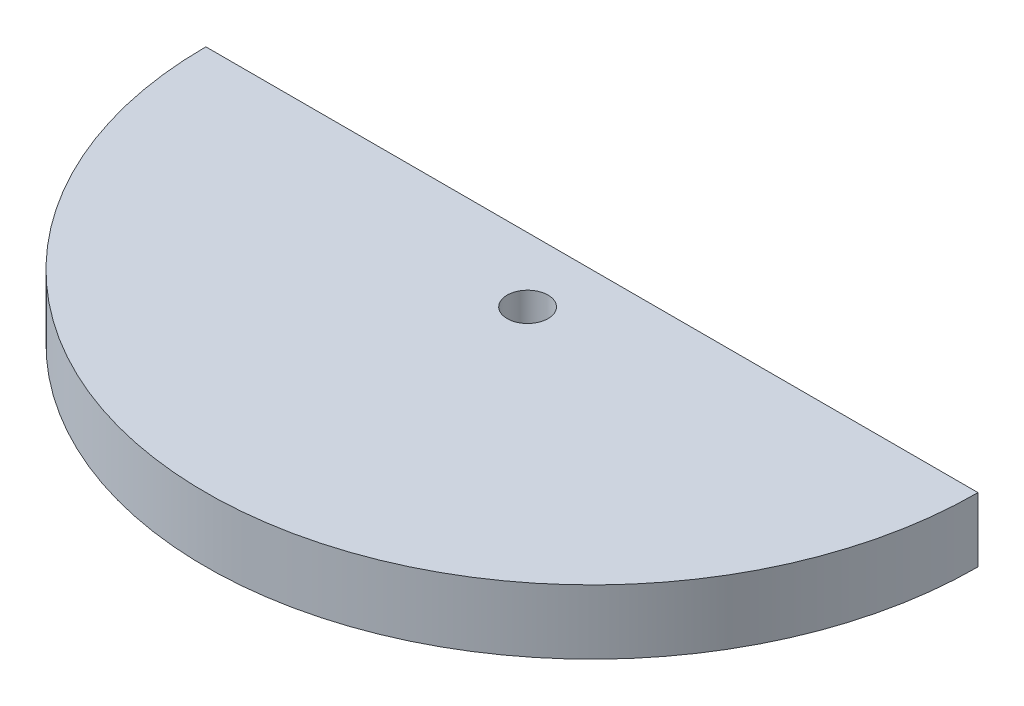
from build123d import *

# Parameters (mm, degrees)
CROQUIS1_R              = 1.5875
SALIENTE_EXTRUIR1_DEPTH = 5


with BuildPart() as part:
    # Croquis1 → Saliente-Extruir1 (new body)
    with BuildSketch(Plane(origin=(0, 0, 0), x_dir=(1, 0, 0), z_dir=(0, 1, 0))):
        with BuildLine():
            Line((-30, 0), (30, 0))
            ThreePointArc((30, 0), (0, -30), (-30, 0))
        make_face()
        with Locations((0, -5)):
            Circle(CROQUIS1_R, mode=Mode.SUBTRACT)
    extrude(amount=SALIENTE_EXTRUIR1_DEPTH)


solid = part.part
